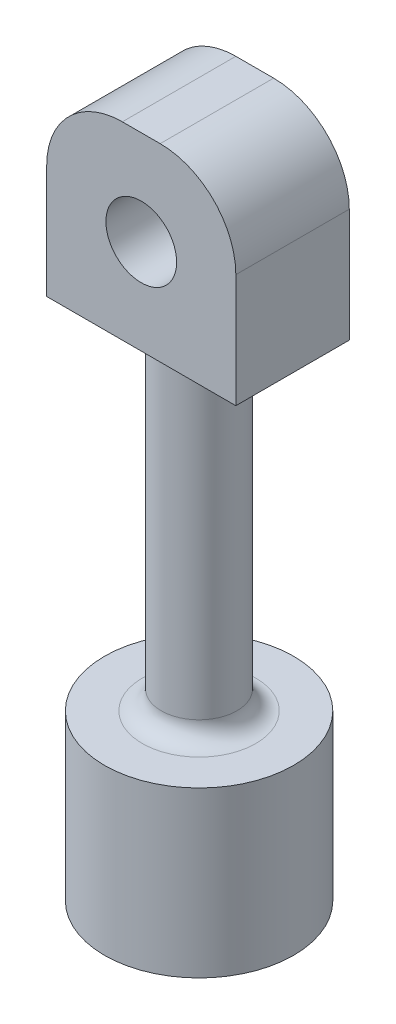
from build123d import *

# Parameters (mm, degrees)
SKETCH1_W           = 5
SKETCH1_H           = 5
SKETCH1_R           = 0.935
BOSS_EXTRUDE3_DEPTH = 3
FILLET3_R           = 2
BOSS_EXTRUDE4_DEPTH = 9
FILLET5_R           = 0.5
SKETCH6_R           = 2.5
BOSS_EXTRUDE5_DEPTH = 4.35
FILLET6_R           = 0.5


with BuildPart() as part:
    # Sketch1 → Boss-Extrude3 (new body)
    with BuildSketch(Plane.XY):
        Rectangle(SKETCH1_W, SKETCH1_H)
        Circle(SKETCH1_R, mode=Mode.SUBTRACT)
    extrude(amount=BOSS_EXTRUDE3_DEPTH)

    # Fillet3
    fillet3_edges = [part.edges().sort_by_distance(p)[0] for p in [
        (-2.5, 2.5, 1.5),
        (2.5, 2.5, 1.5),
    ]]
    fillet(fillet3_edges, radius=FILLET3_R)

    # Sketch3 → Boss-Extrude4 (add)
    with BuildSketch(Plane.XZ.offset(2.5)):
        with BuildLine():
            ThreePointArc((0, 2.471779521), (-1, 1.471779521), (0, 0.471779521))
            Line((0, 0.471779521), (0, 2.471779521))
        make_face()
        with BuildLine():
            Line((0, 2.471779521), (0, 0.471779521))
            ThreePointArc((0, 0.471779521), (0.707106781, 0.76467274), (1, 1.471779521))
            ThreePointArc((1, 1.471779521), (0.707106781, 2.178886302), (0, 2.471779521))
        make_face()
    extrude(amount=BOSS_EXTRUDE4_DEPTH)

    # Fillet5
    fillet5_edges = [part.edges().sort_by_distance(p)[0] for p in [
        (0, -2.5, 0.471779521),
    ]]
    fillet(fillet5_edges, radius=FILLET5_R)

    # Sketch6 → Boss-Extrude5 (add)
    with BuildSketch(Plane.XZ.offset(11.5)):
        with Locations((0, 1.471779521)):
            Circle(SKETCH6_R)
    extrude(amount=BOSS_EXTRUDE5_DEPTH)

    # Fillet6
    fillet6_edges = [part.edges().sort_by_distance(p)[0] for p in [
        (0, -11.5, 0.471779521),
    ]]
    fillet(fillet6_edges, radius=FILLET6_R)


solid = part.part
